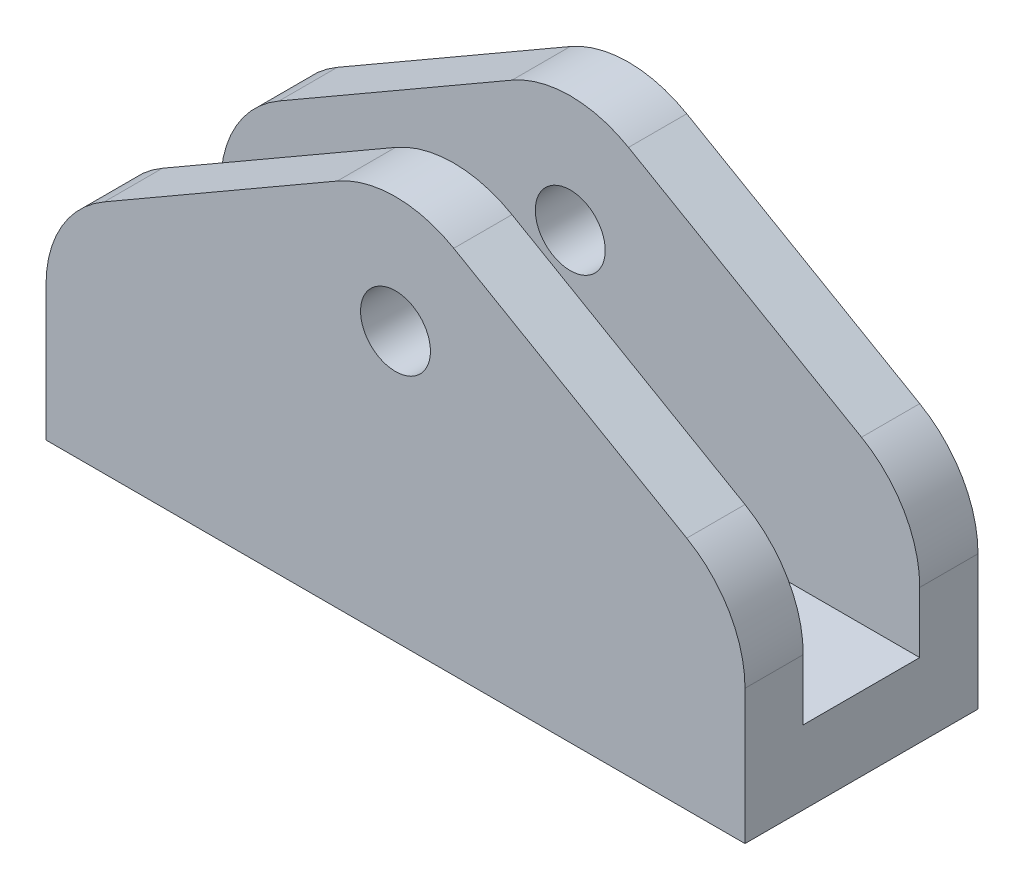
from build123d import *

# Parameters (mm, degrees)
BOSS_EXTRUDE1_DEPTH     = 5
SKETCH2_W               = 30
SKETCH2_H               = 19.460287126
CUT_EXTRUDE1_DEPTH      = 11
FILLET1_R               = 5
SKETCH3_R               = 1.5
CUT_EXTRUDE2_DEPTH      = 11
SKETCH4_W               = 5
SKETCH4_H               = 26.764096408
CUT_EXTRUDE3_DEPTH      = 16
CUT_EXTRUDE3_DEPTH_BACK = 16


with BuildPart() as part:
    # Sketch1 → Boss-Extrude1 (new body, symmetric)
    with BuildSketch(Plane.XY):
        Polygon((0, -17.320508076), (15, -8.660254038), (15, 8.660254038), (0, 17.320508076), (-15, 8.660254038), (-15, -8.660254038), align=None)
    extrude(amount=BOSS_EXTRUDE1_DEPTH, both=True)

    # Sketch2 → Cut-Extrude1 (cut, through all)
    with BuildSketch(Plane.XY.offset(5)):
        with Locations((0, -9.730143563)):
            Rectangle(SKETCH2_W, SKETCH2_H)
    extrude(amount=-CUT_EXTRUDE1_DEPTH, mode=Mode.SUBTRACT)

    # Fillet1
    fillet1_edges = [part.edges().sort_by_distance(p)[0] for p in [
        (-15, 8.660254038, 0),
        (0, 17.320508076, 0),
        (15, 8.660254038, 0),
    ]]
    fillet(fillet1_edges, radius=FILLET1_R)

    # Sketch3 → Cut-Extrude2 (cut, through all)
    with BuildSketch(Plane.XY.offset(5)):
        with Locations((0, 11.547005384)):
            Circle(SKETCH3_R)
    extrude(amount=-CUT_EXTRUDE2_DEPTH, mode=Mode.SUBTRACT)

    # Sketch4 → Cut-Extrude3 (cut, two sides)
    with BuildSketch(Plane(origin=(0, 0, 0), x_dir=(0, 0, -1), z_dir=(1, 0, 0))) as cut_extrude3_sk:
        with Locations((0, 16.547005384)):
            Rectangle(SKETCH4_W, SKETCH4_H)
    extrude(amount=CUT_EXTRUDE3_DEPTH, mode=Mode.SUBTRACT)
    extrude(cut_extrude3_sk.sketch, amount=-CUT_EXTRUDE3_DEPTH_BACK, mode=Mode.SUBTRACT)


solid = part.part
